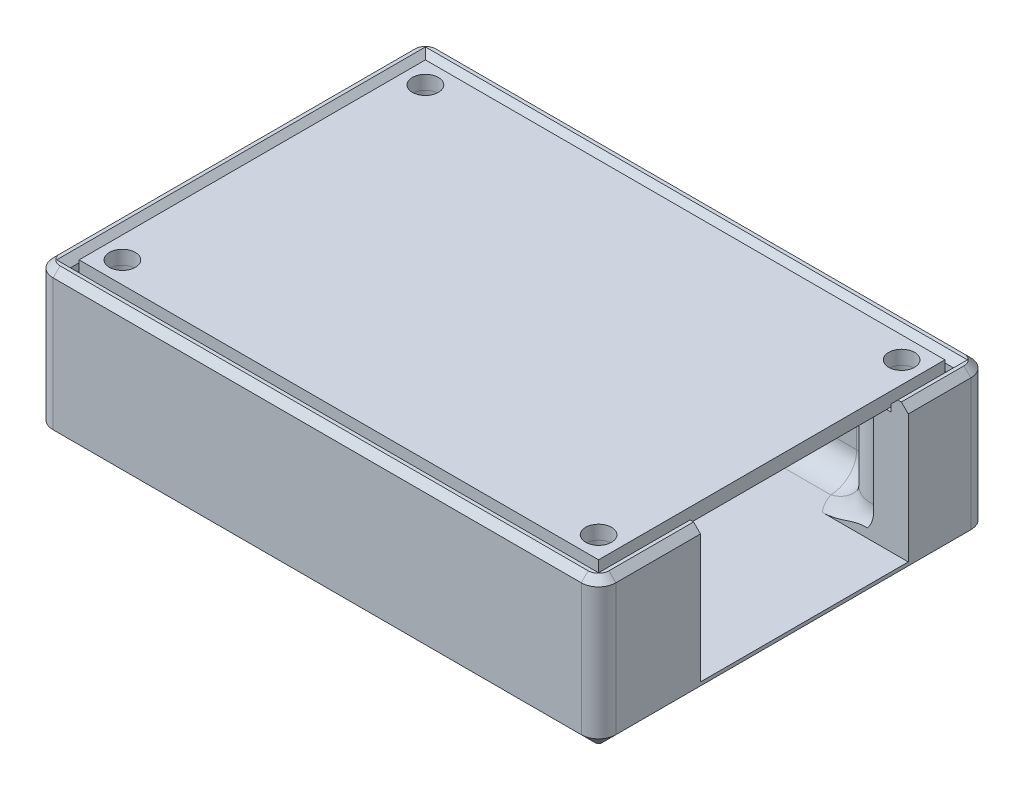
from build123d import *

# Parameters (mm, degrees)
SKETCH1_W           = 60
SKETCH1_H           = 40
SKETCH1_R           = 1.5
BOSS_EXTRUDE1_DEPTH = 1.6
SKETCH2_W           = 65
SKETCH2_H           = 45
SKETCH2_R           = 1.5
BOSS_EXTRUDE2_DEPTH = 14
SKETCH3_W           = 65
SKETCH3_H           = 45
SKETCH3_W_2         = 61
SKETCH3_H_2         = 41
BOSS_EXTRUDE3_DEPTH = 1.6
SKETCH4_W           = 65
SKETCH4_H           = 45
BOSS_EXTRUDE4_DEPTH = 2
FILLET3_R           = 2
FILLET1_R           = 3
FILLET2_R           = 3
CHAMFER1_SIZE       = 1.6
CHAMFER2_SIZE       = 0.8
SKETCH5_W           = 32.5
SKETCH5_H           = 24
CUT_EXTRUDE1_DEPTH  = 15.6


with BuildPart() as part:
    # Sketch1 → Boss-Extrude1 (new body)
    with BuildSketch(Plane(origin=(0, 0, 0), x_dir=(1, 0, 0), z_dir=(0, 1, 0))):
        Rectangle(SKETCH1_W, SKETCH1_H)
        with Locations((27.5, 17.5)):
            Circle(SKETCH1_R, mode=Mode.SUBTRACT)
        with Locations((-27.5, 17.5)):
            Circle(SKETCH1_R, mode=Mode.SUBTRACT)
        with Locations((-27.5, -17.5)):
            Circle(SKETCH1_R, mode=Mode.SUBTRACT)
        with Locations((27.5, -17.5)):
            Circle(SKETCH1_R, mode=Mode.SUBTRACT)
    extrude(amount=BOSS_EXTRUDE1_DEPTH)


with BuildPart() as body_2:
    # Sketch2 → Boss-Extrude2 (new body)
    with BuildSketch(Plane.XZ):
        Rectangle(SKETCH2_W, SKETCH2_H)
        with Locations((-27.5, 17.5)):
            Circle(SKETCH2_R, mode=Mode.SUBTRACT)
        with Locations((27.5, 17.5)):
            Circle(SKETCH2_R, mode=Mode.SUBTRACT)
        with Locations((27.5, -17.5)):
            Circle(SKETCH2_R, mode=Mode.SUBTRACT)
        with Locations((-27.5, -17.5)):
            Circle(SKETCH2_R, mode=Mode.SUBTRACT)
        with BuildLine():
            Line((-24.145898034, 18.5), (24.145898034, 18.5))
            ThreePointArc((24.145898034, 18.5), (25.025126266, 15.025126266), (28.5, 14.145898034))
            Line((28.5, 14.145898034), (28.5, -14.145898034))
            ThreePointArc((28.5, -14.145898034), (25.025126266, -15.025126266), (24.145898034, -18.5))
            Line((24.145898034, -18.5), (-24.145898034, -18.5))
            ThreePointArc((-24.145898034, -18.5), (-26.08747217, -14.297693779), (-30.5, -15.697224362))
            Line((-30.5, -15.697224362), (-30.5, 15.697224362))
            ThreePointArc((-30.5, 15.697224362), (-26.08747217, 14.297693779), (-24.145898034, 18.5))
        make_face(mode=Mode.SUBTRACT)
    extrude(amount=BOSS_EXTRUDE2_DEPTH)

    # Sketch3 → Boss-Extrude3 (add)
    with BuildSketch(Plane(origin=(0, 0, 0), x_dir=(1, 0, 0), z_dir=(0, 1, 0))):
        Rectangle(SKETCH3_W, SKETCH3_H)
        Rectangle(SKETCH3_W_2, SKETCH3_H_2, mode=Mode.SUBTRACT)
    extrude(amount=BOSS_EXTRUDE3_DEPTH)

    # Sketch4 → Boss-Extrude4 (add)
    with BuildSketch(Plane.XZ.offset(14)):
        Rectangle(SKETCH4_W, SKETCH4_H)
    extrude(amount=BOSS_EXTRUDE4_DEPTH)

    # Fillet3
    fillet3_edges = [body_2.edges().sort_by_distance(p)[0] for p in [
        (-32.5, -7.2, -22.5),
        (-32.5, -7.2, 22.5),
        (32.5, -7.2, 22.5),
        (32.5, -7.2, -22.5),
    ]]
    fillet(fillet3_edges, radius=FILLET3_R)

    # Fillet1
    fillet1_edges = [body_2.edges().sort_by_distance(p)[0] for p in [
        (-24.145898034, -7, 18.5),
        (-30.5, -7, 15.697224362),
        (-30.5, -7, -15.697224362),
        (-24.145898034, -7, -18.5),
        (24.145898034, -7, -18.5),
        (28.5, -7, 14.145898034),
        (24.145898034, -7, 18.5),
    ]]
    fillet(fillet1_edges, radius=FILLET1_R)

    # Fillet2
    fillet2_edges = [body_2.edges().sort_by_distance(p)[0] for p in [
        (0, -14, -18.5),
        (25.870937464, -14, -14.402233828),
        (-30.5, -14, 0),
        (-25.440780581, -14, 14.66987361),
        (0, -14, 18.5),
        (25.025126266, -14, 15.025126266),
        (-25.440780581, -14, -14.66987361),
        (-23.080386778, -14, -17.92582262),
        (-29.621320344, -14, -13.121320344),
        (-29.621320344, -14, 13.121320344),
        (-23.080386778, -14, 17.92582262),
        (23.080386778, -14, 17.92582262),
        (27.92582262, -14, 13.080386778),
        (23.080386778, -14, -17.92582262),
        (28.5, -14, -1.415278236),
    ]]
    fillet(fillet2_edges, radius=FILLET2_R)

    # Chamfer1
    chamfer1_edges = [body_2.edges().sort_by_distance(p)[0] for p in [
        (0, -16, 22.5),
        (32.5, -16, 0),
        (0, -16, -22.5),
        (-32.5, -16, 0),
        (-31.914213562, -16, -21.914213562),
        (31.914213562, -16, -21.914213562),
        (-31.914213562, -16, 21.914213562),
        (31.914213562, -16, 21.914213562),
    ]]
    chamfer(chamfer1_edges, length=CHAMFER1_SIZE)

    # Chamfer2
    chamfer2_edges = [body_2.edges().sort_by_distance(p)[0] for p in [
        (0, 1.6, 22.5),
        (0, 1.6, -22.5),
        (-32.5, 1.6, 0),
        (32.5, 1.6, 0),
        (-31.914213562, 1.6, -21.914213562),
        (31.914213562, 1.6, -21.914213562),
        (-31.914213562, 1.6, 21.914213562),
        (31.914213562, 1.6, 21.914213562),
        (0, 1.6, -20.5),
        (-30.5, 1.6, 0),
        (0, 1.6, 20.5),
        (30.5, 1.6, 0),
    ]]
    chamfer(chamfer2_edges, length=CHAMFER2_SIZE)

    # Sketch5 → Cut-Extrude1 (cut)
    with BuildSketch(Plane(origin=(0, 1.6, 0), x_dir=(1, 0, 0), z_dir=(0, 1, 0))):
        with Locations((16.25, 1.27)):
            Rectangle(SKETCH5_W, SKETCH5_H)
    extrude(amount=-CUT_EXTRUDE1_DEPTH, mode=Mode.SUBTRACT)


solid = Compound([part.part, body_2.part])
